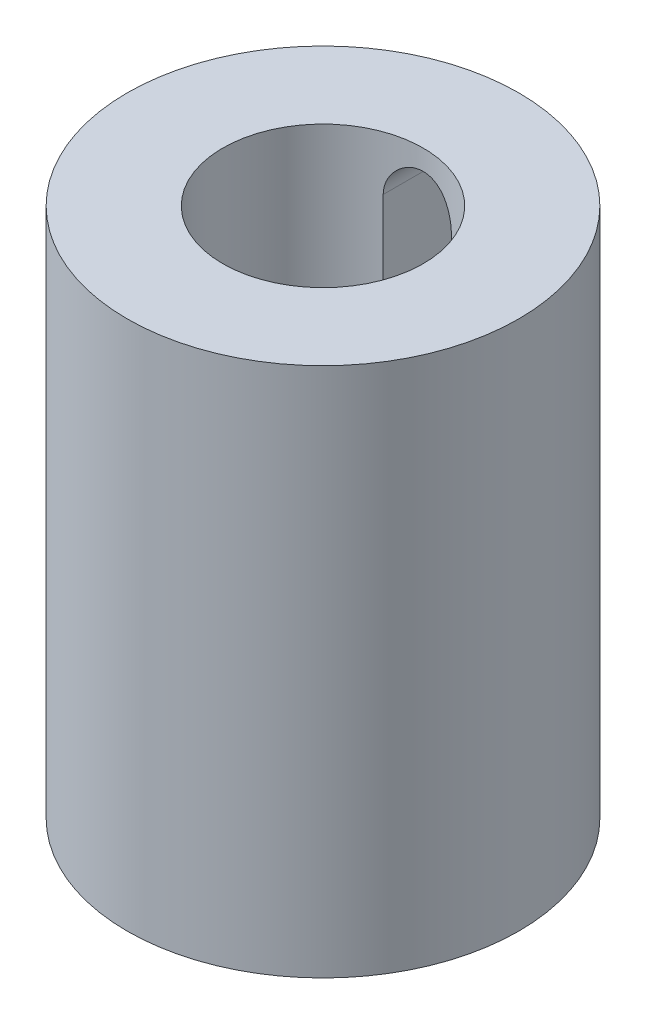
from build123d import *

# Parameters (mm, degrees)
SKETCH1_W          = 14.417582417
SKETCH1_H          = 80
CUT_EXTRUDE1_DEPTH = 30.538461538


with BuildPart() as part:
    # Sketch1 → Revolve1 (revolve)
    with BuildSketch(Plane.XY):
        with Locations((22.32967033, 6.065934066)):
            Rectangle(SKETCH1_W, SKETCH1_H)
    revolve(axis=Axis((0, 46.065934066, 0), (0, -1, 0)))

    # Sketch2 → Cut-Extrude1 (cut, through all)
    with BuildSketch(Plane.XY):
        with BuildLine():
            Line((5.140001029, 37.869690433), (5.140001029, -27.129905913))
            ThreePointArc((5.140001029, -27.129905913), (0, -32.269906942), (-5.140001029, -27.129905913))
            Line((-5.140001029, -27.129905913), (-5.140001029, 37.869690433))
            ThreePointArc((-5.140001029, 37.869690433), (0, 43.009691462), (5.140001029, 37.869690433))
        make_face()
    extrude(amount=-CUT_EXTRUDE1_DEPTH, mode=Mode.SUBTRACT)


solid = part.part
